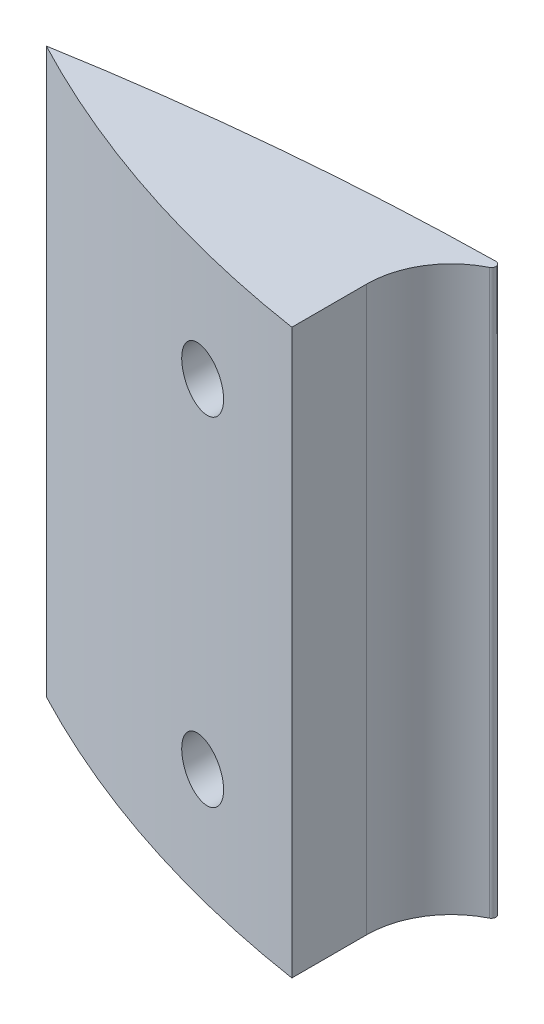
from build123d import *

# Parameters (mm, degrees)
BOSS_EXTRUDE1_DEPTH = 31.75
SKETCH2_R           = 1.5875
CUT_EXTRUDE1_DEPTH  = 9.980818595


with BuildPart() as part:
    # Sketch1 → Boss-Extrude1 (new body)
    with BuildSketch(Plane(origin=(0, 0, 0), x_dir=(1, 0, 0), z_dir=(0, 1, 0))):
        with BuildLine():
            Line((-4.7625, 144.4625), (-4.7625, 140.244181405))
            ThreePointArc((-4.7625, 140.244181405), (-15.362391405, 142.792956785), (-25.4, 147.047409447))
            ThreePointArc((-25.4, 147.047409447), (-13.860926819, 148.579861801), (-2.237511623, 149.208224193))
            ThreePointArc((-2.237511623, 149.208224193), (-1.986877125, 149.014193897), (-2.120604202, 148.726822228))
            ThreePointArc((-2.120604202, 148.726822228), (-4.048504895, 146.97068946), (-4.7625, 144.4625))
        make_face()
    extrude(amount=BOSS_EXTRUDE1_DEPTH)

    # Sketch2 → Cut-Extrude1 (cut, through all)
    with BuildSketch(Plane(origin=(0, 0, -149.225), x_dir=(-1, 0, 0), z_dir=(0, 0, -1))):
        with Locations((11.1125, 25.4)):
            Circle(SKETCH2_R)
        with Locations((11.1125, 6.35)):
            Circle(SKETCH2_R)
    extrude(amount=-CUT_EXTRUDE1_DEPTH, mode=Mode.SUBTRACT)


solid = part.part
